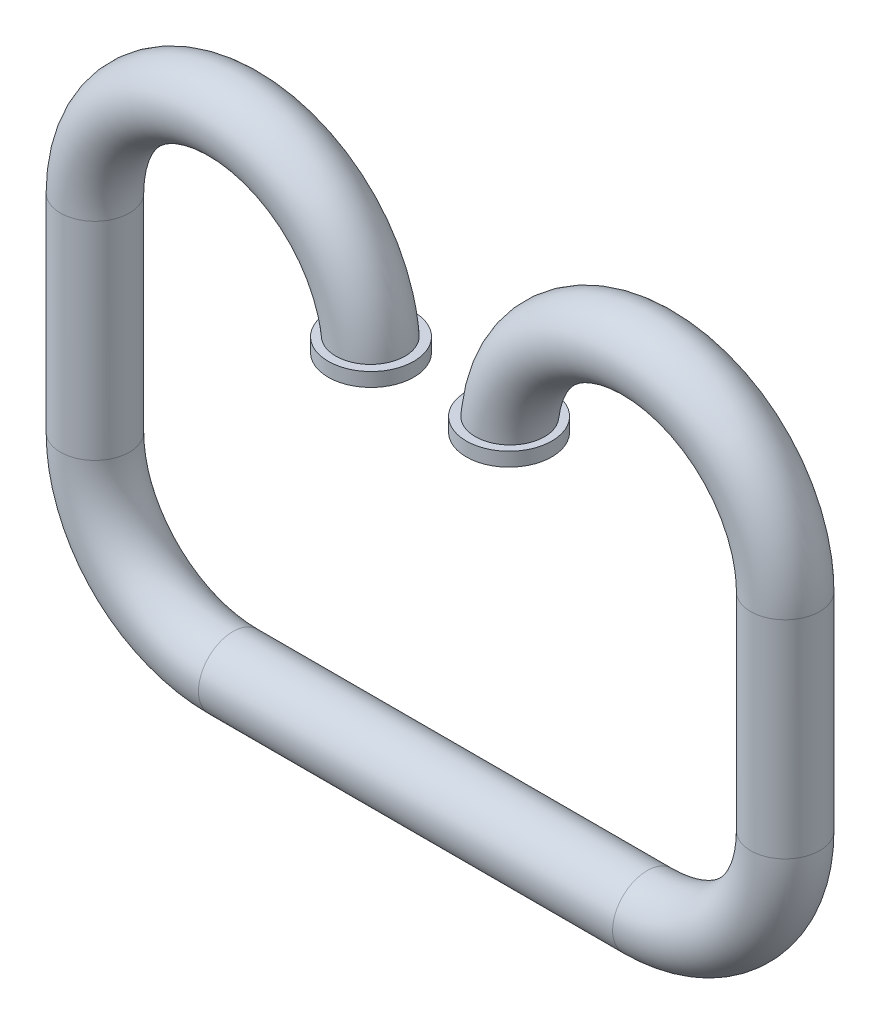
from build123d import *

# Parameters (mm, degrees)
SKETCH3_R   = 0.25
SKETCH3_R_2 = 0.2
SKETCH6_R   = 0.31
SKETCH6_R_2 = 0.21


with BuildPart() as part:
    # Sweep-Thin1: sweep along a path in Sketch1
    with BuildLine(Plane.XY) as sweep_thin1_path:
        Line((0.5, -2.5), (-1, -2.5))
        ThreePointArc((-1, -2.5), (-1.707106781, -2.207106781), (-2, -1.5))
        Line((-2, -1.5), (-2, 0))
        ThreePointArc((-2, 0), (-1, 1), (0, 0))
    # Sketch3 → Sweep-Thin1 (sweep)
    with BuildSketch(Plane(origin=(0, 0, 0), x_dir=(1, 0, 0), z_dir=(0, 1, 0))):
        Circle(SKETCH3_R)
        Circle(SKETCH3_R_2, mode=Mode.SUBTRACT)
    sweep(path=sweep_thin1_path.line)

    # Sweep-Thin2: sweep along a path in Sketch5
    with BuildLine(Plane.XY) as sweep_thin2_path:
        Line((0, 0), (0, 0.1))
    # Sketch6 → Sweep-Thin2 (sweep)
    with BuildSketch(Plane(origin=(0, 0, 0), x_dir=(1, 0, 0), z_dir=(0, 1, 0))):
        Circle(SKETCH6_R)
        Circle(SKETCH6_R_2, mode=Mode.SUBTRACT)
    sweep(path=sweep_thin2_path.line)

    # Mirror2: part across plane


with BuildPart() as part_1:
    add(part.part)
    add(part.part.mirror(Plane(origin=(0.5, -2.5, 0), x_dir=(0, 0, 1), z_dir=(1, 0, 0))))


solid = part_1.part
